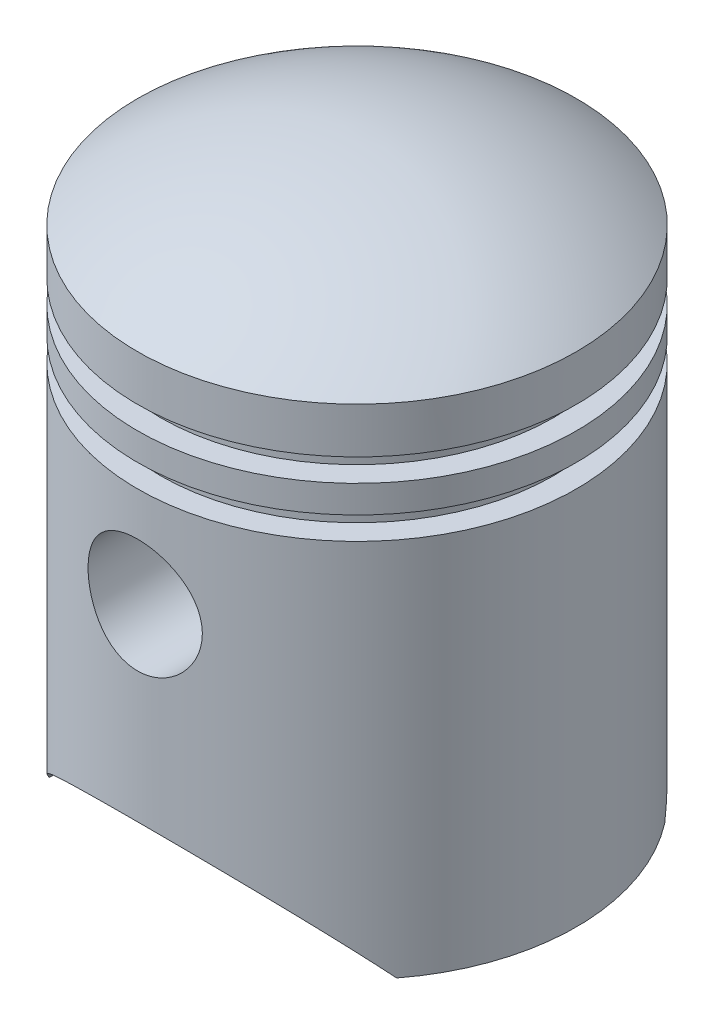
from build123d import *

# Parameters (mm, degrees)
CUT_EXTRUDE1_DEPTH      = 241
CUT_EXTRUDE1_DEPTH_BACK = 241
SKETCH4_R               = 62.5
CUT_EXTRUDE2_DEPTH      = 241.0000001
CUT_EXTRUDE2_DEPTH_BACK = 241.0000001
BOSS_EXTRUDE1_REACH     = 122
SKETCH5_R               = 72.5
SKETCH5_R_2             = 62.5


with BuildPart() as part:
    # Sketch1 → Revolve2 (revolve)
    with BuildSketch(Plane.XY):
        with BuildLine():
            Line((0, 625), (0, 605))
            ThreePointArc((0, 605), (115.458447667, 587.035007786), (220, 534.838667697))
            Line((220, 534.838667697), (220, 515))
            Line((220, 515), (195, 515))
            Line((195, 515), (195, 455))
            Line((195, 455), (195, 395))
            Line((195, 395), (220, 395))
            Line((220, 395), (220, 0))
            Line((220, 0), (240, 0))
            Line((240, 0), (240, 415))
            Line((240, 415), (215, 415))
            Line((215, 415), (215, 440))
            Line((215, 440), (240, 440))
            Line((240, 440), (240, 470))
            Line((240, 470), (215, 470))
            Line((215, 470), (215, 495))
            Line((215, 495), (240, 495))
            Line((240, 495), (240, 545))
            ThreePointArc((240, 545), (126.491106407, 604.47331922), (0, 625))
        make_face()
    revolve(axis=Axis((0, 625, 0), (0, -1, 0)))

    # Sketch2 → Cut-Extrude1 (cut, two sides)
    with BuildSketch(Plane.XY) as cut_extrude1_sk:
        with BuildLine():
            Line((-190, 0), (190, 0))
            ThreePointArc((190, 0), (0, 99.55454139), (-190, 0))
        make_face()
    extrude(amount=CUT_EXTRUDE1_DEPTH, mode=Mode.SUBTRACT)
    extrude(cut_extrude1_sk.sketch, amount=-CUT_EXTRUDE1_DEPTH_BACK, mode=Mode.SUBTRACT)

    # Sketch4 → Cut-Extrude2 (cut, two sides)
    with BuildSketch(Plane.XY) as cut_extrude2_sk:
        with Locations((0, 305)):
            Circle(SKETCH4_R)
    extrude(amount=CUT_EXTRUDE2_DEPTH, mode=Mode.SUBTRACT)
    extrude(cut_extrude2_sk.sketch, amount=-CUT_EXTRUDE2_DEPTH_BACK, mode=Mode.SUBTRACT)

    # Sketch5 → Boss-Extrude1 (add, up to next)
    with BuildSketch(Plane.XY.offset(120), mode=Mode.PRIVATE) as boss_extrude1_sk1:
        with Locations((0, 305)):
            Circle(SKETCH5_R)
        with Locations((0, 305)):
            Circle(SKETCH5_R_2, mode=Mode.SUBTRACT)
    boss_extrude1_tool1 = extrude(boss_extrude1_sk1.sketch, amount=BOSS_EXTRUDE1_REACH, mode=Mode.PRIVATE) - part.part
    add(boss_extrude1_tool1.solids().sort_by_distance((-70.44939, 305, 120))[0])

    # Mirror1: part across plane


with BuildPart() as part_1:
    add(part.part)
    add(part.part.mirror(Plane.XY))


solid = part_1.part
